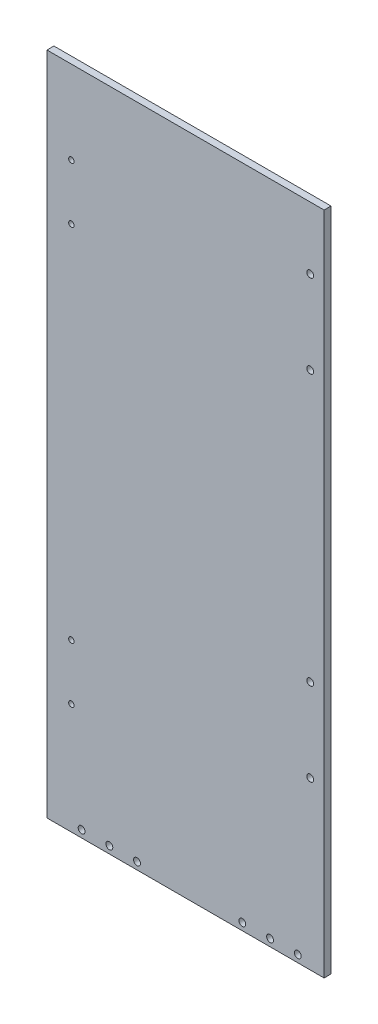
from build123d import *

# Parameters (mm, degrees)
SKETCH1_W           = 254
SKETCH1_H           = 609.6
BOSS_EXTRUDE1_DEPTH = 6.35
SKETCH2_R           = 2.4638
CUT_EXTRUDE1_DEPTH  = 7.35
SKETCH3_R           = 3.175
CUT_EXTRUDE2_DEPTH  = 6.35
SKETCH4_R           = 3.175
CUT_EXTRUDE3_DEPTH  = 6.35


with BuildPart() as part:
    # Sketch1 → Boss-Extrude1 (new body)
    with BuildSketch(Plane.XY):
        with Locations((-127, -539.261538462)):
            Rectangle(SKETCH1_W, SKETCH1_H)
    extrude(amount=BOSS_EXTRUDE1_DEPTH)

    # Sketch2 → Cut-Extrude1 (cut, through all)
    with BuildSketch(Plane.XY.offset(6.35)):
        with Locations((-231.648, -310.661538462)):
            Circle(SKETCH2_R)
        with Locations((-231.648, -361.461538462)):
            Circle(SKETCH2_R)
        with Locations((-231.648, -691.661538462)):
            Circle(SKETCH2_R)
        with Locations((-231.648, -742.461538462)):
            Circle(SKETCH2_R)
    extrude(amount=-CUT_EXTRUDE1_DEPTH, mode=Mode.SUBTRACT)

    # Sketch3 → Cut-Extrude2 (cut)
    with BuildSketch(Plane(origin=(0, 0, 0), x_dir=(-1, 0, 0), z_dir=(0, 0, -1))):
        with Locations((24.13, -837.457538462)):
            Circle(SKETCH3_R)
        with Locations((49.53, -837.457538462)):
            Circle(SKETCH3_R)
        with Locations((74.991555208, -837.457538462)):
            Circle(SKETCH3_R)
        with Locations((196.85, -837.457538462)):
            Circle(SKETCH3_R)
        with Locations((171.45, -837.457538462)):
            Circle(SKETCH3_R)
        with Locations((222.25, -837.457538462)):
            Circle(SKETCH3_R)
    extrude(amount=-CUT_EXTRUDE2_DEPTH, mode=Mode.SUBTRACT)

    # Sketch4 → Cut-Extrude3 (cut)
    with BuildSketch(Plane.XY.offset(6.35)):
        with Locations((-12.7, -291.611538462)):
            Circle(SKETCH4_R)
        with Locations((-12.7, -367.811538462)):
            Circle(SKETCH4_R)
        with Locations((-12.7, -691.661538462)):
            Circle(SKETCH4_R)
        with Locations((-12.7, -615.461538462)):
            Circle(SKETCH4_R)
    extrude(amount=-CUT_EXTRUDE3_DEPTH, mode=Mode.SUBTRACT)


solid = part.part
